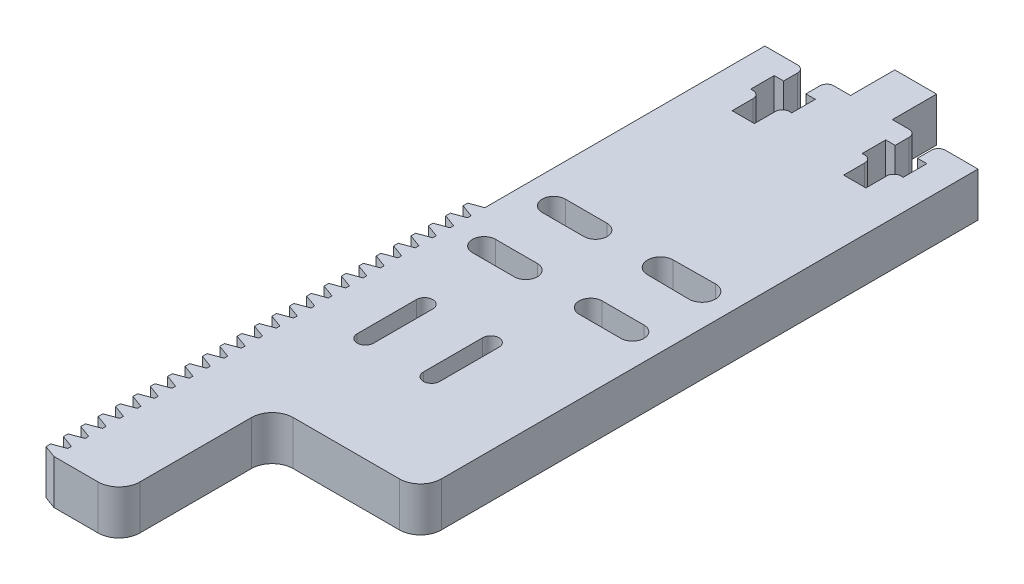
from build123d import *

# Parameters (mm, degrees)
BOSS_EXTRUDE1_DEPTH = 6.35
CUT_EXTRUDE1_DEPTH  = 7.35
CUT_EXTRUDE2_DEPTH  = 7.35
CUT_EXTRUDE3_DEPTH  = 7.35
CUT_EXTRUDE4_DEPTH  = 7.35
CUT_EXTRUDE5_DEPTH  = 7.35
CUT_EXTRUDE6_DEPTH  = 7.35
FILLET1_R           = 1
FILLET2_R           = 3
SKETCH8_W           = 6
SKETCH8_H           = 6.35
BOSS_EXTRUDE2_DEPTH = 6.35


with BuildPart() as part:
    # Sketch1 → Boss-Extrude1 (new body)
    with BuildSketch(Plane(origin=(0, 6.35, 0), x_dir=(1, 0, 0), z_dir=(0, 1, 0))):
        with BuildLine():
            Line((28.524769042, 95.779182639), (28.524769042, 99.149566194))
            Line((28.524769042, 99.149566194), (29.874769042, 99.149566194))
            Line((29.874769042, 99.149566194), (29.874769042, 102.149566194))
            Line((29.874769042, 102.149566194), (17.074769042, 102.149566194))
            Line((17.074769042, 102.149566194), (17.074769042, 99.149566194))
            Line((17.074769042, 99.149566194), (18.424769042, 99.149566194))
            Line((18.424769042, 99.149566194), (18.424769042, 95.77323607))
            Line((18.424769042, 95.77323607), (17.074769042, 95.77323607))
            Line((17.074769042, 95.77323607), (17.074769042, 91.759160166))
            Line((17.074769042, 91.759160166), (13.874769042, 91.759160166))
            Line((13.874769042, 91.759160166), (13.874769042, 95.77323607))
            Line((13.874769042, 95.77323607), (12.524769042, 95.77323607))
            Line((12.524769042, 95.77323607), (12.524769042, 99.149566194))
            Line((12.524769042, 99.149566194), (13.874769042, 99.149566194))
            Line((13.874769042, 99.149566194), (13.874769042, 102.149566194))
            Line((13.874769042, 102.149566194), (8.185694042, 102.149566194))
            Line((8.185694042, 102.149566194), (8.185694042, 61.970735216))
            Line((8.185694042, 61.970735216), (6.388694042, 61.316680705))
            Line((6.388694042, 61.316680705), (6.388694042, 60.647620705))
            Line((6.388694042, 60.647620705), (8.185694042, 59.993566194))
            Line((8.185694042, 59.993566194), (8.185694042, 59.477235216))
            Line((8.185694042, 59.477235216), (6.388694042, 58.823180705))
            Line((6.388694042, 58.823180705), (6.388694042, 58.154120705))
            Line((6.388694042, 58.154120705), (8.185694042, 57.500066194))
            Line((8.185694042, 57.500066194), (8.185694042, 56.983735216))
            Line((8.185694042, 56.983735216), (6.388694042, 56.329680705))
            Line((6.388694042, 56.329680705), (6.388694042, 55.660620705))
            Line((6.388694042, 55.660620705), (8.185694042, 55.006566194))
            Line((8.185694042, 55.006566194), (8.185694042, 54.490235216))
            Line((8.185694042, 54.490235216), (6.388694042, 53.836180705))
            Line((6.388694042, 53.836180705), (6.388694042, 53.167120705))
            Line((6.388694042, 53.167120705), (8.185694042, 52.513066194))
            Line((8.185694042, 52.513066194), (8.185694042, 51.996735216))
            Line((8.185694042, 51.996735216), (6.388694042, 51.342680705))
            Line((6.388694042, 51.342680705), (6.388694042, 50.673620705))
            Line((6.388694042, 50.673620705), (8.185694042, 50.019566194))
            Line((8.185694042, 50.019566194), (8.185694042, 49.503235216))
            Line((8.185694042, 49.503235216), (6.388694042, 48.849180705))
            Line((6.388694042, 48.849180705), (6.388694042, 48.180120705))
            Line((6.388694042, 48.180120705), (8.185694042, 47.526066194))
            Line((8.185694042, 47.526066194), (8.185694042, 47.009735216))
            Line((8.185694042, 47.009735216), (6.388694042, 46.355680705))
            Line((6.388694042, 46.355680705), (6.388694042, 45.686620705))
            Line((6.388694042, 45.686620705), (8.185694042, 45.032566194))
            Line((8.185694042, 45.032566194), (8.185694042, 44.516235216))
            Line((8.185694042, 44.516235216), (6.388694042, 43.862180705))
            Line((6.388694042, 43.862180705), (6.388694042, 43.193120705))
            Line((6.388694042, 43.193120705), (8.185694042, 42.539066194))
            Line((8.185694042, 42.539066194), (8.185694042, 42.022735216))
            Line((8.185694042, 42.022735216), (6.388694042, 41.368680705))
            Line((6.388694042, 41.368680705), (6.388694042, 40.699620705))
            Line((6.388694042, 40.699620705), (8.185694042, 40.045566194))
            Line((8.185694042, 40.045566194), (8.185694042, 39.529235216))
            Line((8.185694042, 39.529235216), (6.388694042, 38.875180705))
            Line((6.388694042, 38.875180705), (6.388694042, 38.206120705))
            Line((6.388694042, 38.206120705), (8.185694042, 37.552066194))
            Line((8.185694042, 37.552066194), (8.185694042, 37.035735216))
            Line((8.185694042, 37.035735216), (6.388694042, 36.381680705))
            Line((6.388694042, 36.381680705), (6.388694042, 35.712620705))
            Line((6.388694042, 35.712620705), (8.185694042, 35.058566194))
            Line((8.185694042, 35.058566194), (8.185694042, 34.542235216))
            Line((8.185694042, 34.542235216), (6.388694042, 33.888180705))
            Line((6.388694042, 33.888180705), (6.388694042, 33.219120705))
            Line((6.388694042, 33.219120705), (8.185694042, 32.565066194))
            Line((8.185694042, 32.565066194), (8.185694042, 32.048735216))
            Line((8.185694042, 32.048735216), (6.388694042, 31.394680705))
            Line((6.388694042, 31.394680705), (6.388694042, 30.725620705))
            Line((6.388694042, 30.725620705), (8.185694042, 30.071566194))
            Line((8.185694042, 30.071566194), (8.185694042, 29.555235216))
            Line((8.185694042, 29.555235216), (6.388694042, 28.901180705))
            Line((6.388694042, 28.901180705), (6.388694042, 28.232120705))
            Line((6.388694042, 28.232120705), (8.185694042, 27.578066194))
            Line((8.185694042, 27.578066194), (8.185694042, 27.061735216))
            Line((8.185694042, 27.061735216), (6.388694042, 26.407680705))
            Line((6.388694042, 26.407680705), (6.388694042, 25.738620705))
            Line((6.388694042, 25.738620705), (8.185694042, 25.084566194))
            Line((8.185694042, 25.084566194), (8.185694042, 24.568235216))
            Line((8.185694042, 24.568235216), (6.388694042, 23.914180705))
            Line((6.388694042, 23.914180705), (6.388694042, 23.245120705))
            Line((6.388694042, 23.245120705), (8.185694042, 22.591066194))
            Line((8.185694042, 22.591066194), (8.185694042, 22.074735216))
            Line((8.185694042, 22.074735216), (6.388694042, 21.420680705))
            Line((6.388694042, 21.420680705), (6.388694042, 20.751620705))
            Line((6.388694042, 20.751620705), (8.185694042, 20.097566194))
            Line((8.185694042, 20.097566194), (8.185694042, 19.581235216))
            Line((8.185694042, 19.581235216), (6.388694042, 18.927180705))
            Line((6.388694042, 18.927180705), (6.388694042, 18.258120705))
            Line((6.388694042, 18.258120705), (8.185694042, 17.604066194))
            Line((8.185694042, 17.604066194), (8.185694042, 17.087735216))
            Line((8.185694042, 17.087735216), (6.388694042, 16.433680705))
            Line((6.388694042, 16.433680705), (6.388694042, 15.764620705))
            Line((6.388694042, 15.764620705), (8.185694042, 15.110566194))
            Line((8.185694042, 15.110566194), (8.185694042, 14.594235216))
            Line((8.185694042, 14.594235216), (6.388694042, 13.940180705))
            Line((6.388694042, 13.940180705), (6.388694042, 13.271120705))
            Line((6.388694042, 13.271120705), (8.185694042, 12.617066194))
            Line((8.185694042, 12.617066194), (8.185694042, 12.100735216))
            Line((8.185694042, 12.100735216), (6.388694042, 11.446680705))
            Line((6.388694042, 11.446680705), (6.388694042, 10.777620705))
            Line((6.388694042, 10.777620705), (8.185694042, 10.123566194))
            Line((8.185694042, 10.123566194), (8.185694042, 9.607235216))
            Line((8.185694042, 9.607235216), (6.388694042, 8.953180705))
            Line((6.388694042, 8.953180705), (6.388694042, 8.284120705))
            Line((6.388694042, 8.284120705), (8.185694042, 7.630066194))
            Line((8.185694042, 7.630066194), (8.185694042, 7.113735216))
            Line((8.185694042, 7.113735216), (6.388694042, 6.459680705))
            Line((6.388694042, 6.459680705), (6.388694042, 5.790620705))
            Line((6.388694042, 5.790620705), (8.185694042, 5.136566194))
            Line((8.185694042, 5.136566194), (8.185694042, 4.620235216))
            Line((8.185694042, 4.620235216), (6.388694042, 3.966180705))
            Line((6.388694042, 3.966180705), (6.388694042, 3.297120705))
            Line((6.388694042, 3.297120705), (8.185694042, 2.643066194))
            Line((8.185694042, 2.643066194), (8.185694042, 2.126735216))
            Line((8.185694042, 2.126735216), (6.388694042, 1.472680705))
            Line((6.388694042, 1.472680705), (6.388694042, 0.803620705))
            Line((6.388694042, 0.803620705), (8.185694042, 0.149566194))
            Line((8.185694042, 0.149566194), (14.513844042, 0.149566194))
            ThreePointArc((14.513844042, 0.149566194), (16.635164386, 1.028245851), (17.513844042, 3.149566194))
            Line((17.513844042, 3.149566194), (17.513844042, 22.149566194))
            Line((17.513844042, 22.149566194), (35.763844042, 22.149566194))
            ThreePointArc((35.763844042, 22.149566194), (37.885164386, 23.028245851), (38.763844042, 25.149566194))
            Line((38.763844042, 25.149566194), (38.763844042, 102.149566194))
            Line((38.763844042, 102.149566194), (33.074769044, 102.149566194))
            Line((33.074769044, 102.149566194), (33.074769044, 99.149566194))
            Line((33.074769044, 99.149566194), (34.424769044, 99.149566194))
            Line((34.424769044, 99.149566194), (34.424769044, 95.753230748))
            Line((34.424769044, 95.753230748), (33.074769044, 95.759168893))
            Line((33.074769044, 95.759168893), (33.074769044, 91.759160166))
            Line((33.074769044, 91.759160166), (29.874769042, 91.759160166))
            Line((29.874769042, 91.759160166), (29.874769042, 95.773244495))
            Line((29.874769042, 95.773244495), (28.524769042, 95.779182639))
        make_face()
    extrude(amount=-BOSS_EXTRUDE1_DEPTH)

    # Sketch2 → Cut-Extrude1 (cut, through all)
    with BuildSketch(Plane(origin=(0, 6.35, 0), x_dir=(-1, 0, 0), z_dir=(0, 1, 0))):
        with BuildLine():
            Line((-24.188844042, -45.649566194), (-24.188844042, -37.149566194))
            ThreePointArc((-24.188844042, -37.149566194), (-25.363844042, -35.974566194), (-26.538844042, -37.149566194))
            Line((-26.538844042, -37.149566194), (-26.538844042, -45.649566194))
            ThreePointArc((-26.538844042, -45.649566194), (-25.363844042, -46.824566194), (-24.188844042, -45.649566194))
        make_face()
    extrude(amount=-CUT_EXTRUDE1_DEPTH, mode=Mode.SUBTRACT)

    # Sketch3 → Cut-Extrude2 (cut, through all)
    with BuildSketch(Plane(origin=(0, 6.35, 0), x_dir=(-1, 0, 0), z_dir=(0, 1, 0))):
        with BuildLine():
            Line((-12.887404555, -55.491566194), (-18.887404555, -55.491566194))
            ThreePointArc((-18.887404555, -55.491566194), (-20.545404555, -57.149566194), (-18.887404555, -58.807566194))
            Line((-18.887404555, -58.807566194), (-12.887404555, -58.807566194))
            ThreePointArc((-12.887404555, -58.807566194), (-11.229404555, -57.149566194), (-12.887404555, -55.491566194))
        make_face()
    extrude(amount=-CUT_EXTRUDE2_DEPTH, mode=Mode.SUBTRACT)

    # Sketch4 → Cut-Extrude3 (cut, through all)
    with BuildSketch(Plane(origin=(0, 6.35, 0), x_dir=(-1, 0, 0), z_dir=(0, 1, 0))):
        with BuildLine():
            Line((-18.887404555, -68.807712194), (-12.887404555, -68.807712194))
            ThreePointArc((-12.887404555, -68.807712194), (-11.229258555, -67.149566194), (-12.887404555, -65.491420194))
            Line((-12.887404555, -65.491420194), (-18.887404555, -65.491420194))
            ThreePointArc((-18.887404555, -65.491420194), (-20.545550555, -67.149566194), (-18.887404555, -68.807712194))
        make_face()
    extrude(amount=-CUT_EXTRUDE3_DEPTH, mode=Mode.SUBTRACT)

    # Sketch5 → Cut-Extrude4 (cut, through all)
    with BuildSketch(Plane(origin=(0, 6.35, 0), x_dir=(-1, 0, 0), z_dir=(0, 1, 0))):
        with BuildLine():
            Line((-28.18674425, -55.49156871), (-34.18674425, -55.49156871))
            ThreePointArc((-34.18674425, -55.49156871), (-35.844740476, -57.149564936), (-34.18674425, -58.807561163))
            Line((-34.18674425, -58.807561163), (-28.18674425, -58.807561163))
            ThreePointArc((-28.18674425, -58.807561163), (-26.528748023, -57.149564936), (-28.18674425, -55.49156871))
        make_face()
    extrude(amount=-CUT_EXTRUDE4_DEPTH, mode=Mode.SUBTRACT)

    # Sketch6 → Cut-Extrude5 (cut, through all)
    with BuildSketch(Plane(origin=(0, 6.35, 0), x_dir=(-1, 0, 0), z_dir=(0, 1, 0))):
        with BuildLine():
            Line((-28.167982116, -65.30916533), (-34.167358649, -65.248006406))
            ThreePointArc((-34.167358649, -65.248006406), (-36.088402147, -67.149566194), (-34.167358649, -69.051125982))
            Line((-34.167358649, -69.051125982), (-28.167982116, -68.989967058))
            ThreePointArc((-28.167982116, -68.989967058), (-26.346247064, -67.149566194), (-28.167982116, -65.30916533))
        make_face()
    extrude(amount=-CUT_EXTRUDE5_DEPTH, mode=Mode.SUBTRACT)

    # Sketch7 → Cut-Extrude6 (cut, through all)
    with BuildSketch(Plane.XZ):
        with BuildLine():
            Line((14.687531887, -37.149566194), (14.687531887, -45.649566194))
            ThreePointArc((14.687531887, -45.649566194), (15.862531908, -46.824566216), (17.03753193, -45.649566194))
            Line((17.03753193, -45.649566194), (17.03753193, -37.149566194))
            ThreePointArc((17.03753193, -37.149566194), (15.862531908, -35.974566173), (14.687531887, -37.149566194))
        make_face()
    extrude(amount=-CUT_EXTRUDE6_DEPTH, mode=Mode.SUBTRACT)

    # Fillet1
    fillet1_edges = [part.edges().sort_by_distance(p)[0] for p in [
        (29.874769042, 3.175, -95.773244495),
        (33.074769044, 3.175, -95.759168893),
        (33.074769044, 3.175, -102.149566194),
        (13.874769042, 3.175, -102.149566194),
        (13.874769042, 3.175, -95.77323607),
        (17.074769042, 3.175, -95.77323607),
        (17.074769042, 3.175, -102.149566194),
        (29.874769042, 3.175, -102.149566194),
    ]]
    fillet(fillet1_edges, radius=FILLET1_R)

    # Fillet2
    fillet2_edges = [part.edges().sort_by_distance(p)[0] for p in [
        (17.513844042, 3.175, -22.149566194),
    ]]
    fillet(fillet2_edges, radius=FILLET2_R)

    # Sketch8 → Boss-Extrude2 (add)
    with BuildSketch(Plane(origin=(0, 6.35, 0), x_dir=(1, 0, 0), z_dir=(0, 1, 0))):
        with Locations((23.474769042, 105.324566194)):
            Rectangle(SKETCH8_W, SKETCH8_H)
    extrude(amount=-BOSS_EXTRUDE2_DEPTH)


solid = part.part
